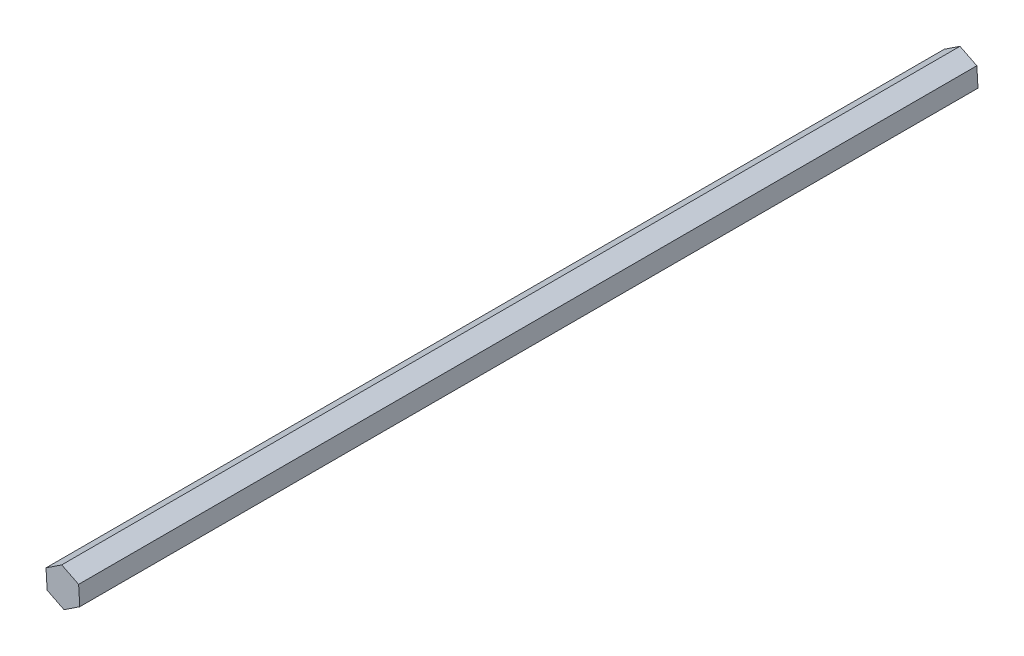
from build123d import *

# Parameters (mm, degrees)
BOSS_EXTRUDE1_DEPTH = 350


with BuildPart() as part:
    # Sketch1 → Boss-Extrude1 (new body)
    with BuildSketch(Plane.XY):
        Polygon((-0.45377191, 7.335979216), (-6.580030318, 3.275011606), (-6.126258407, -4.06096761), (0.45377191, -7.335979216), (6.580030318, -3.275011606), (6.126258407, 4.06096761), align=None)
    extrude(amount=BOSS_EXTRUDE1_DEPTH)


solid = part.part
